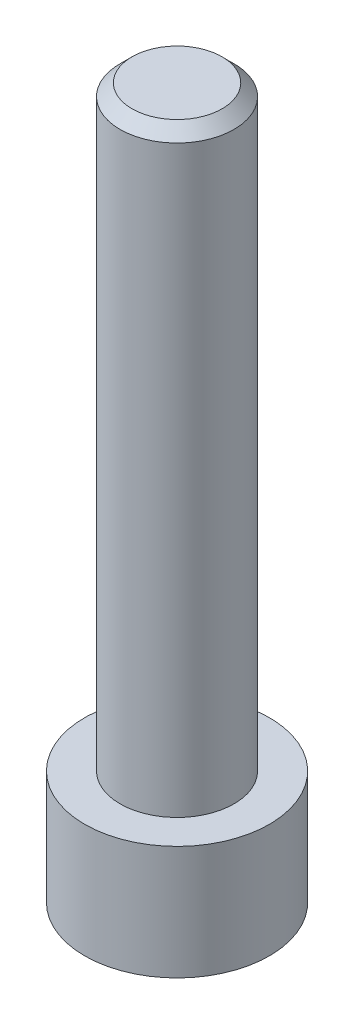
from build123d import *

# Parameters (mm, degrees)
SKETCH1_R           = 3.875
BOSS_EXTRUDE1_DEPTH = 29.78
SKETCH2_OUTSIDE_W   = 16.096
SKETCH2_OUTSIDE_H   = 16.096
SKETCH2_OUTSIDE_R   = 2.39
CUT_EXTRUDE1_DEPTH  = 25
CHAMFER1_SIZE       = 0.5
CUT_EXTRUDE2_DEPTH  = 3.36


with BuildPart() as part:
    # Sketch1 → Boss-Extrude1 (new body)
    with BuildSketch(Plane(origin=(0, 0, 0), x_dir=(1, 0, 0), z_dir=(0, 1, 0))):
        Circle(SKETCH1_R)
    extrude(amount=BOSS_EXTRUDE1_DEPTH)

    # Sketch2 outside → Cut-Extrude1 (cut)
    with BuildSketch(Plane(origin=(0, 29.78, 0), x_dir=(1, 0, 0), z_dir=(0, 1, 0))):
        Rectangle(SKETCH2_OUTSIDE_W, SKETCH2_OUTSIDE_H)
        Circle(SKETCH2_OUTSIDE_R, mode=Mode.SUBTRACT)
    extrude(amount=-CUT_EXTRUDE1_DEPTH, mode=Mode.SUBTRACT)

    # Chamfer1
    chamfer1_edges = [part.edges().sort_by_distance(p)[0] for p in [
        (-2.39, 29.78, 0),
    ]]
    chamfer(chamfer1_edges, length=CHAMFER1_SIZE)

    # Sketch8 → Cut-Extrude2 (cut)
    with BuildSketch(Plane.XZ):
        Polygon((2.644264233, 0), (1.322132116, 2.29), (-1.322132116, 2.29), (-2.644264233, 0), (-1.322132116, -2.29), (1.322132116, -2.29), align=None)
    extrude(amount=-CUT_EXTRUDE2_DEPTH, mode=Mode.SUBTRACT)


solid = part.part
